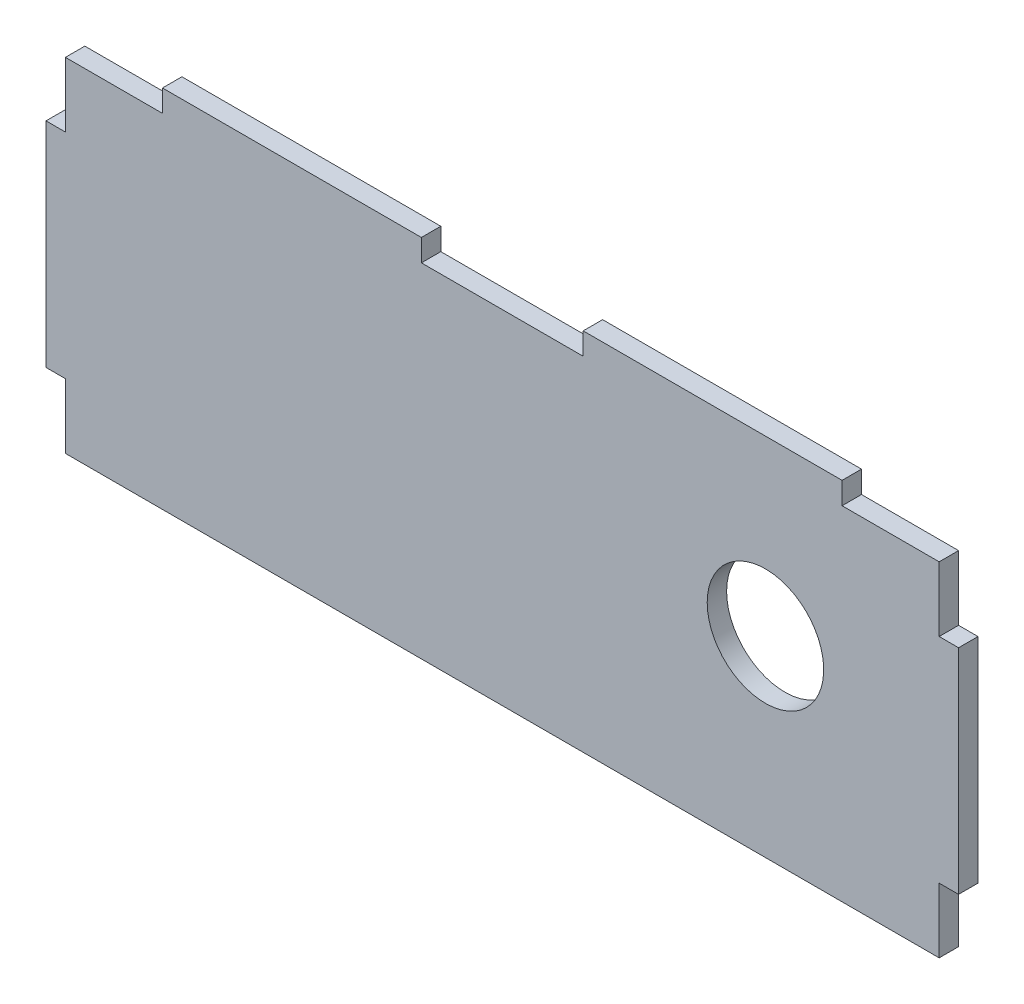
from build123d import *

# Parameters (mm, degrees)
ESQUISSE1_W             = 135
ESQUISSE1_H             = 53
BOSS_EXTRU_1_DEPTH      = 3
ESQUISSE2_R             = 9
ENL_V_MAT_EXTRU_1_DEPTH = 4
ESQUISSE3_W             = 3
ESQUISSE3_H             = 33
BOSS_EXTRU_2_DEPTH      = 3
ESQUISSE4_W             = 3
ESQUISSE4_H             = 33
BOSS_EXTRU_3_DEPTH      = 3
ESQUISSE5_W             = 40
ESQUISSE5_H             = 3
BOSS_EXTRU_4_DEPTH      = 3.4
ESQUISSE6_W             = 40
ESQUISSE6_H             = 3
BOSS_EXTRU_5_DEPTH      = 3.4


with BuildPart() as part:
    # Esquisse1 → Boss.-Extru.1 (new body)
    with BuildSketch(Plane.XY):
        with Locations((-41.062592566, -45.035528327)):
            Rectangle(ESQUISSE1_W, ESQUISSE1_H)
    extrude(amount=BOSS_EXTRU_1_DEPTH)

    # Esquisse2 → Enlèv. mat.-Extru.1 (cut, through all)
    with BuildSketch(Plane(origin=(0, 0, 0), x_dir=(-1, 0, 0), z_dir=(0, 0, -1))):
        with Locations((0.403677713, -41.89919031)):
            Circle(ESQUISSE2_R)
    extrude(amount=-ENL_V_MAT_EXTRU_1_DEPTH, mode=Mode.SUBTRACT)

    # Esquisse3 → Boss.-Extru.2 (add)
    with BuildSketch(Plane(origin=(26.437407434, 0, 0), x_dir=(0, 0, -1), z_dir=(1, 0, 0))):
        with Locations((-1.5, -45.035528327)):
            Rectangle(ESQUISSE3_W, ESQUISSE3_H)
    extrude(amount=BOSS_EXTRU_2_DEPTH)

    # Esquisse4 → Boss.-Extru.3 (add)
    with BuildSketch(Plane.ZY.offset(108.562592566)):
        with Locations((1.5, -45.035528327)):
            Rectangle(ESQUISSE4_W, ESQUISSE4_H)
    extrude(amount=BOSS_EXTRU_3_DEPTH)

    # Esquisse5 → Boss.-Extru.4 (add)
    with BuildSketch(Plane(origin=(0, -18.535528327, 0), x_dir=(1, 0, 0), z_dir=(0, 1, 0))):
        with Locations((-73.562592566, -1.5)):
            Rectangle(ESQUISSE5_W, ESQUISSE5_H)
    extrude(amount=BOSS_EXTRU_4_DEPTH)

    # Esquisse6 → Boss.-Extru.5 (add)
    with BuildSketch(Plane(origin=(0, -18.535528327, 0), x_dir=(1, 0, 0), z_dir=(0, 1, 0))):
        with Locations((-8.562592566, -1.5)):
            Rectangle(ESQUISSE6_W, ESQUISSE6_H)
    extrude(amount=BOSS_EXTRU_5_DEPTH)


solid = part.part
